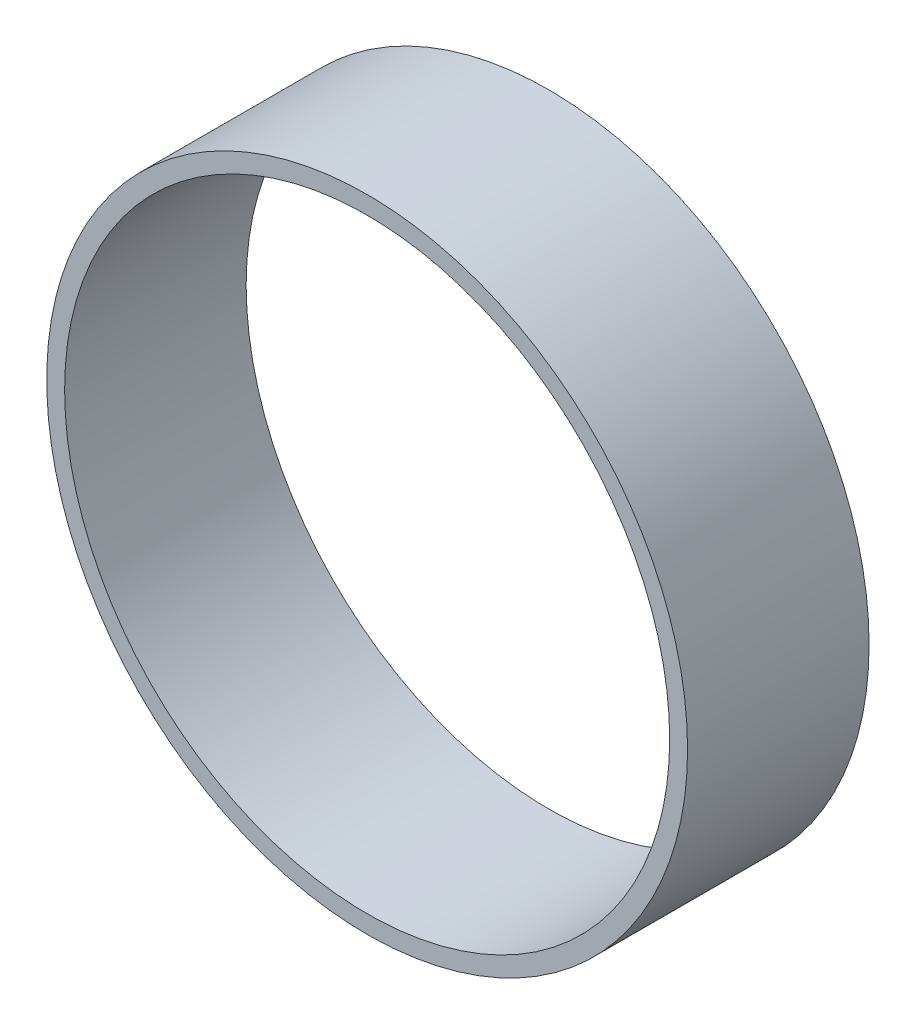
from build123d import *

# Parameters (mm, degrees)
SKETCH1_R           = 40.354130995
SKETCH1_R_2         = 38.1
BOSS_EXTRUDE1_DEPTH = 22.86


with BuildPart() as part:
    # Sketch1 → Boss-Extrude1 (new body)
    with BuildSketch(Plane.XY):
        Circle(SKETCH1_R)
        Circle(SKETCH1_R_2, mode=Mode.SUBTRACT)
    extrude(amount=BOSS_EXTRUDE1_DEPTH)


solid = part.part
